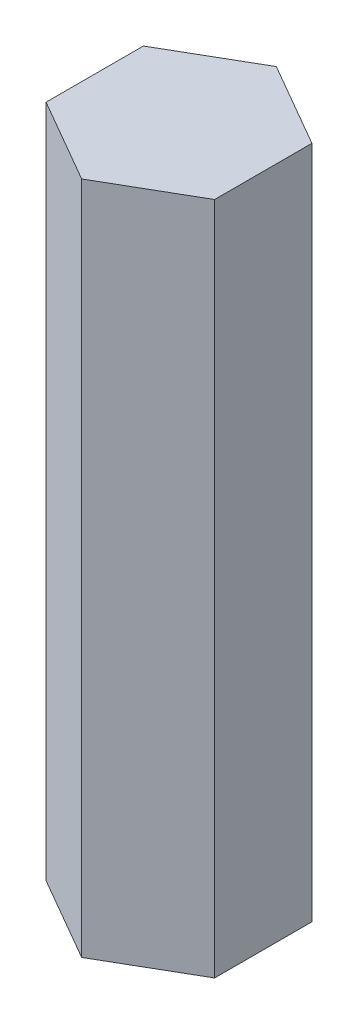
from build123d import *

# Parameters (mm, degrees)
BOSS_EXTRUDE1_DEPTH = 50.8


with BuildPart() as part:
    # Sketch1 → Boss-Extrude1 (new body)
    with BuildSketch(Plane(origin=(0, 0, 0), x_dir=(1, 0, 0), z_dir=(0, 1, 0))):
        Polygon((0, 7.332348419), (-6.35, 3.666174209), (-6.35, -3.666174209), (0, -7.332348419), (6.35, -3.666174209), (6.35, 3.666174209), align=None)
    extrude(amount=BOSS_EXTRUDE1_DEPTH)


solid = part.part
